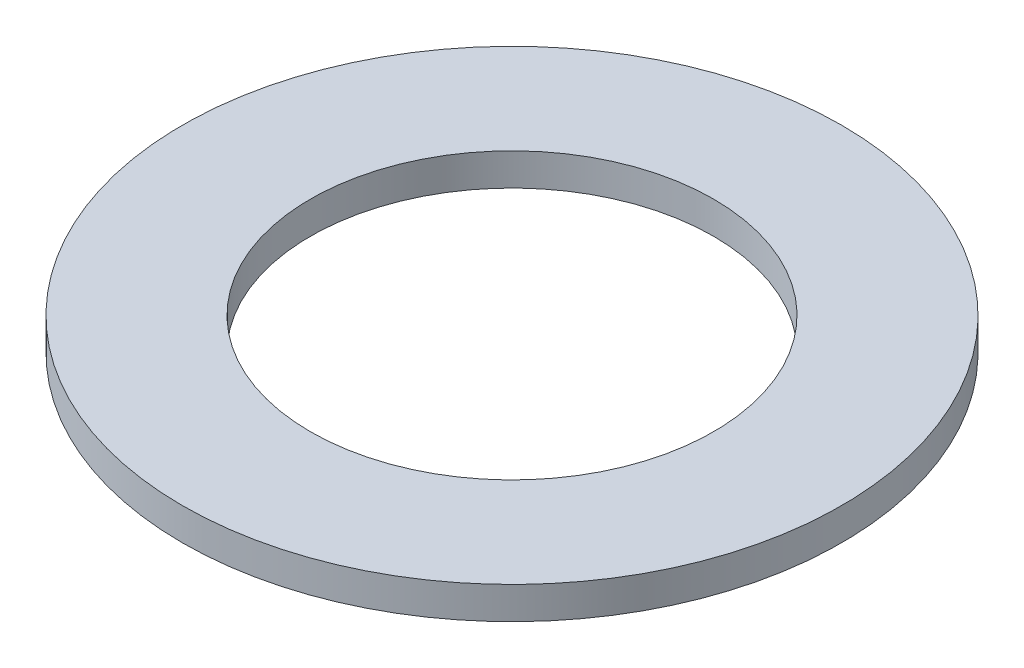
from build123d import *

# Parameters (mm, degrees)
SKETCH2_R           = 8.175
SKETCH2_R_2         = 5
BOSS_EXTRUDE2_DEPTH = 0.8


with BuildPart() as part:
    # Sketch2 → Boss-Extrude2 (new body)
    with BuildSketch(Plane(origin=(0, 0, 0), x_dir=(1, 0, 0), z_dir=(0, 1, 0))):
        Circle(SKETCH2_R)
        Circle(SKETCH2_R_2, mode=Mode.SUBTRACT)
    extrude(amount=BOSS_EXTRUDE2_DEPTH)


solid = part.part
